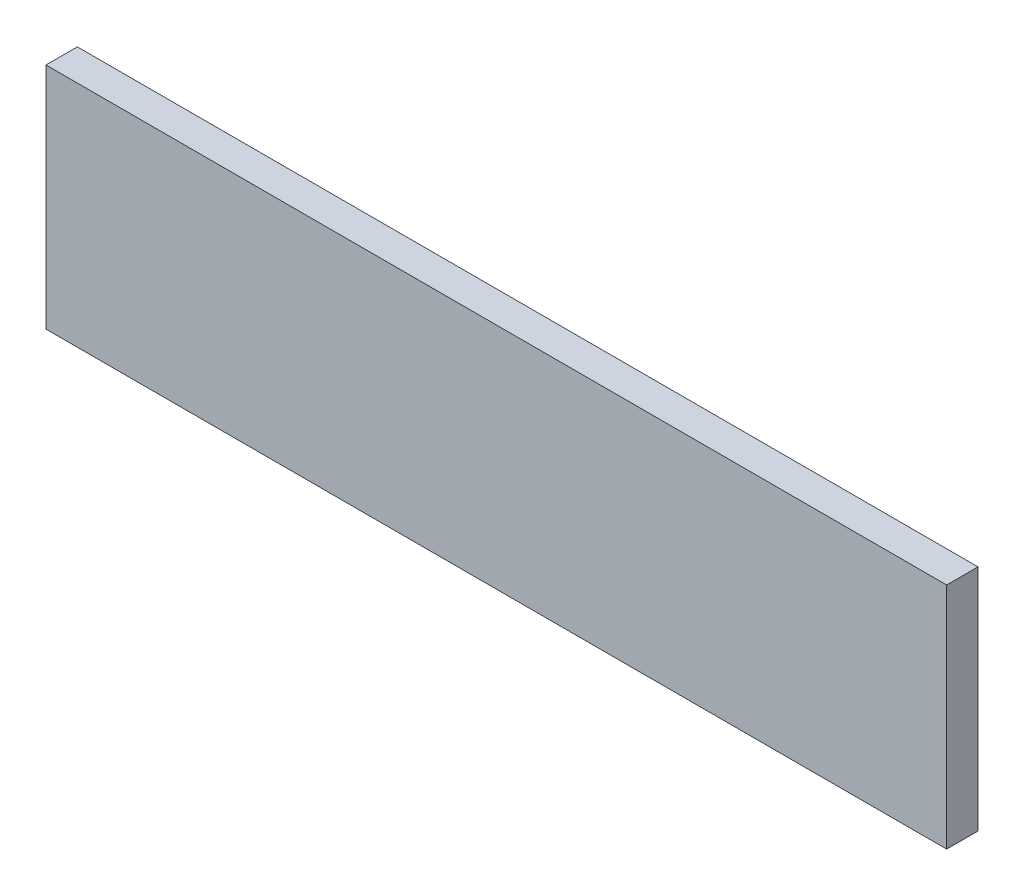
from build123d import *

# Parameters (mm, degrees)
SKETCH1_W           = 273.600000032
SKETCH1_H           = 69.5
BOSS_EXTRUDE1_DEPTH = 9.525


with BuildPart() as part:
    # Sketch1 → Boss-Extrude1 (new body)
    with BuildSketch(Plane.XY):
        with Locations((-117, 34.75)):
            Rectangle(SKETCH1_W, SKETCH1_H)
    extrude(amount=-BOSS_EXTRUDE1_DEPTH)


solid = part.part
